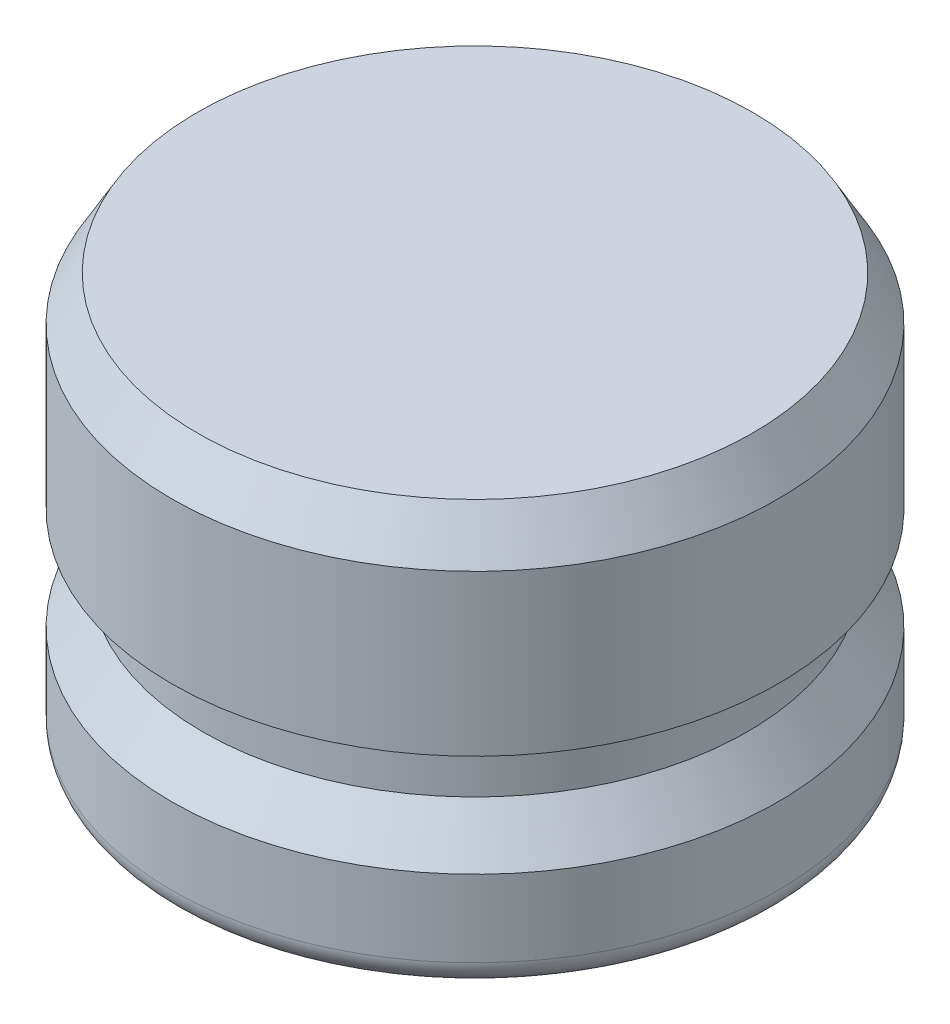
from build123d import *

# Parameters (mm, degrees)
FILLET1_R      = 0.79375
CHAMFER1_SIZE  = 0.79375
CHAMFER1_SIZE2 = 1.374815329


with BuildPart() as part:
    # Sketch1 → Revolve1 (revolve)
    with BuildSketch(Plane.XY):
        Polygon((0, 0), (-9.4234, 0), (-9.4234, 3.175), (-8.4582, 4.572), (-8.4582, 6.35), (-9.4234, 6.35), (-9.4234, 12.7), (0, 12.7), align=None)
    revolve(axis=Axis((0, 0, 0), (0, 1, 0)))

    # Fillet1
    fillet1_edges = [part.edges().sort_by_distance(p)[0] for p in [
        (9.4234, 0, 0),
    ]]
    fillet(fillet1_edges, radius=FILLET1_R)

    # Chamfer1
    chamfer1_edges = [part.edges().sort_by_distance(p)[0] for p in [
        (9.4234, 12.7, 0),
    ]]
    chamfer1_side = [part.faces().sort_by_distance(p)[0] for p in [
        (0, 12.7, 0),
    ]]
    chamfer(chamfer1_edges, length=CHAMFER1_SIZE, length2=CHAMFER1_SIZE2, reference=chamfer1_side[0])


solid = part.part
